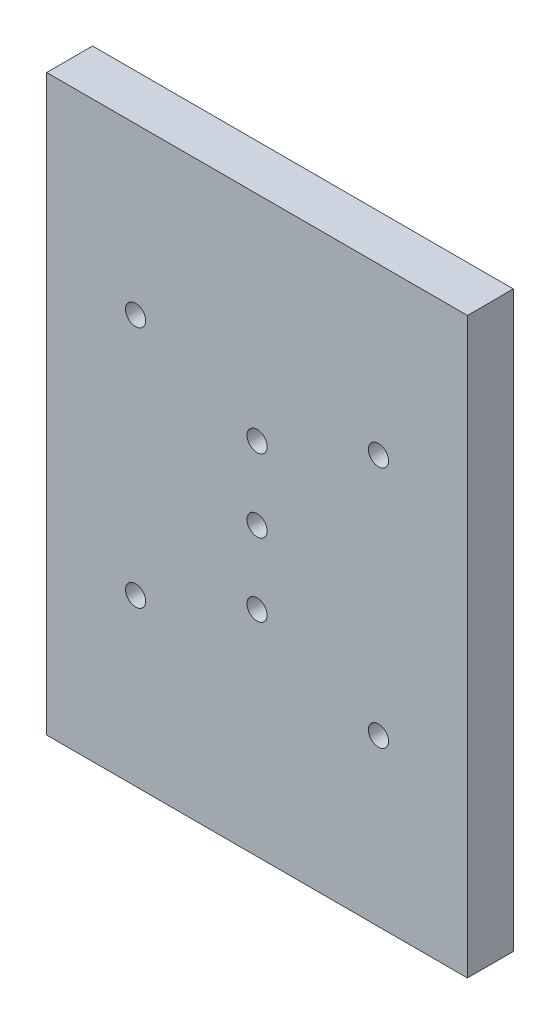
from build123d import *

# Parameters (mm, degrees)
SKETCH1_W           = 55
SKETCH1_H           = 75
SKETCH1_R           = 1.32
BOSS_EXTRUDE1_DEPTH = 6
SKETCH2_R           = 3.25
CUT_EXTRUDE1_DEPTH  = 4


with BuildPart() as part:
    # Sketch1 → Boss-Extrude1 (new body)
    with BuildSketch(Plane.XY):
        with Locations((-27.5, -37.5)):
            Rectangle(SKETCH1_W, SKETCH1_H)
        with Locations((-43.375, -21.625)):
            Circle(SKETCH1_R, mode=Mode.SUBTRACT)
        with Locations((-11.625, -21.625)):
            Circle(SKETCH1_R, mode=Mode.SUBTRACT)
        with Locations((-11.625, -53.375)):
            Circle(SKETCH1_R, mode=Mode.SUBTRACT)
        with Locations((-43.375, -53.375)):
            Circle(SKETCH1_R, mode=Mode.SUBTRACT)
        with Locations((-27.5, -27.97)):
            Circle(SKETCH1_R, mode=Mode.SUBTRACT)
        with Locations((-27.5, -37.5)):
            Circle(SKETCH1_R, mode=Mode.SUBTRACT)
        with Locations((-27.5, -47.03)):
            Circle(SKETCH1_R, mode=Mode.SUBTRACT)
    extrude(amount=BOSS_EXTRUDE1_DEPTH)

    # Sketch2 → Cut-Extrude1 (cut)
    with BuildSketch(Plane(origin=(0, 0, 0), x_dir=(-1, 0, 0), z_dir=(0, 0, -1))):
        with Locations((11.625, -21.625)):
            Circle(SKETCH2_R)
        with Locations((43.375, -21.625)):
            Circle(SKETCH2_R)
        with Locations((43.375, -53.375)):
            Circle(SKETCH2_R)
        with Locations((11.625, -53.375)):
            Circle(SKETCH2_R)
    extrude(amount=-CUT_EXTRUDE1_DEPTH, mode=Mode.SUBTRACT)


solid = part.part
